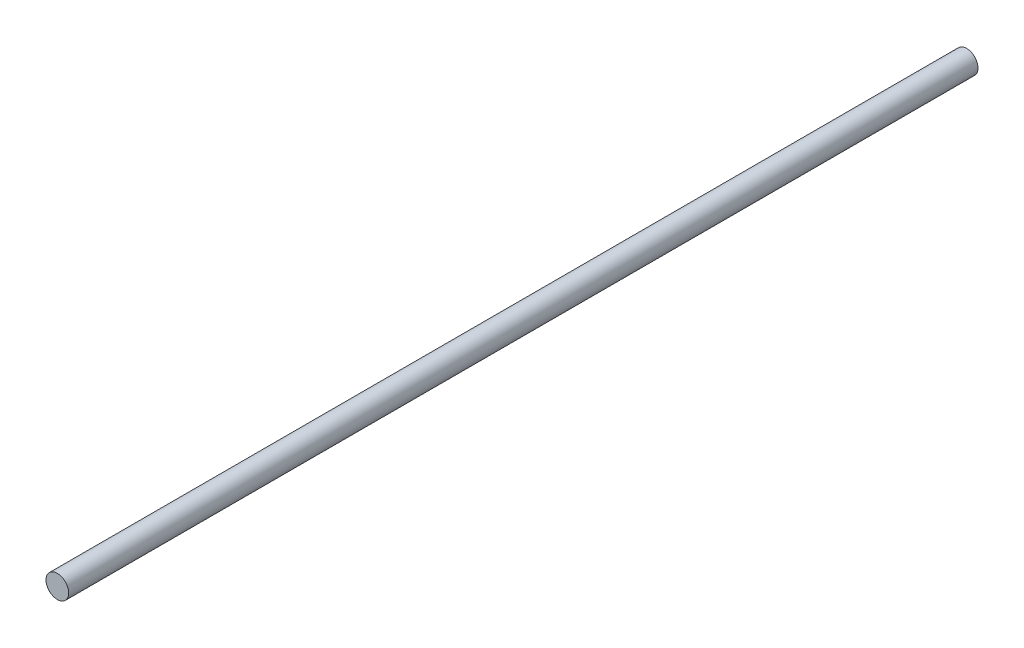
from build123d import *

# Parameters (mm, degrees)
SKETCH1_R           = 10
BOSS_EXTRUDE1_DEPTH = 800


with BuildPart() as part:
    # Sketch1 → Boss-Extrude1 (new body)
    with BuildSketch(Plane.XY):
        Circle(SKETCH1_R)
    extrude(amount=BOSS_EXTRUDE1_DEPTH)


solid = part.part
